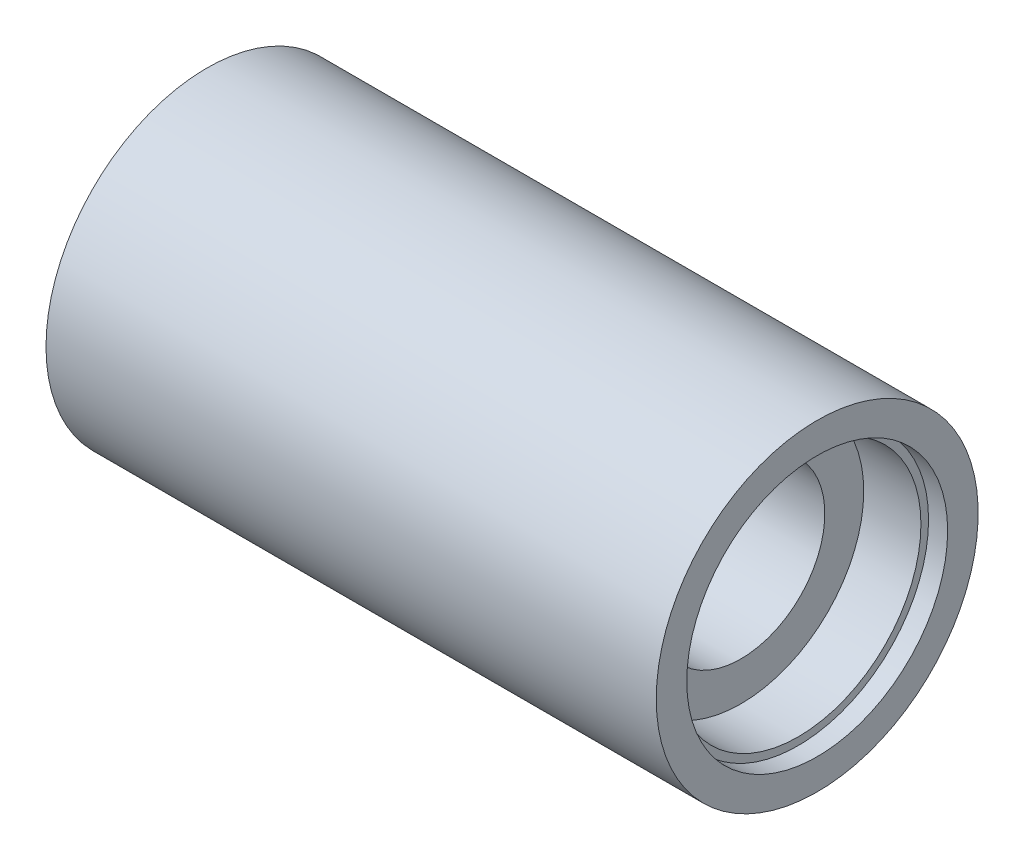
from build123d import *


with BuildPart() as part:
    # Sketch1 → Revolve1 (revolve)
    with BuildSketch(Plane.XY):
        Polygon((0, 21.1), (40, 21.1), (40, 17.1), (37.5, 17.1), (37.5, 16.1), (30, 16.1), (30, 11), (0, 11), align=None)
    revolve1 = revolve(axis=Axis((0, 0, 0), (1, 0, 0)))

    # Mirror1: Revolve1 across plane
    add(revolve1.mirror(Plane(origin=(0, 0, 0), x_dir=(0, 0, 1), z_dir=(1, 0, 0))))


solid = part.part
